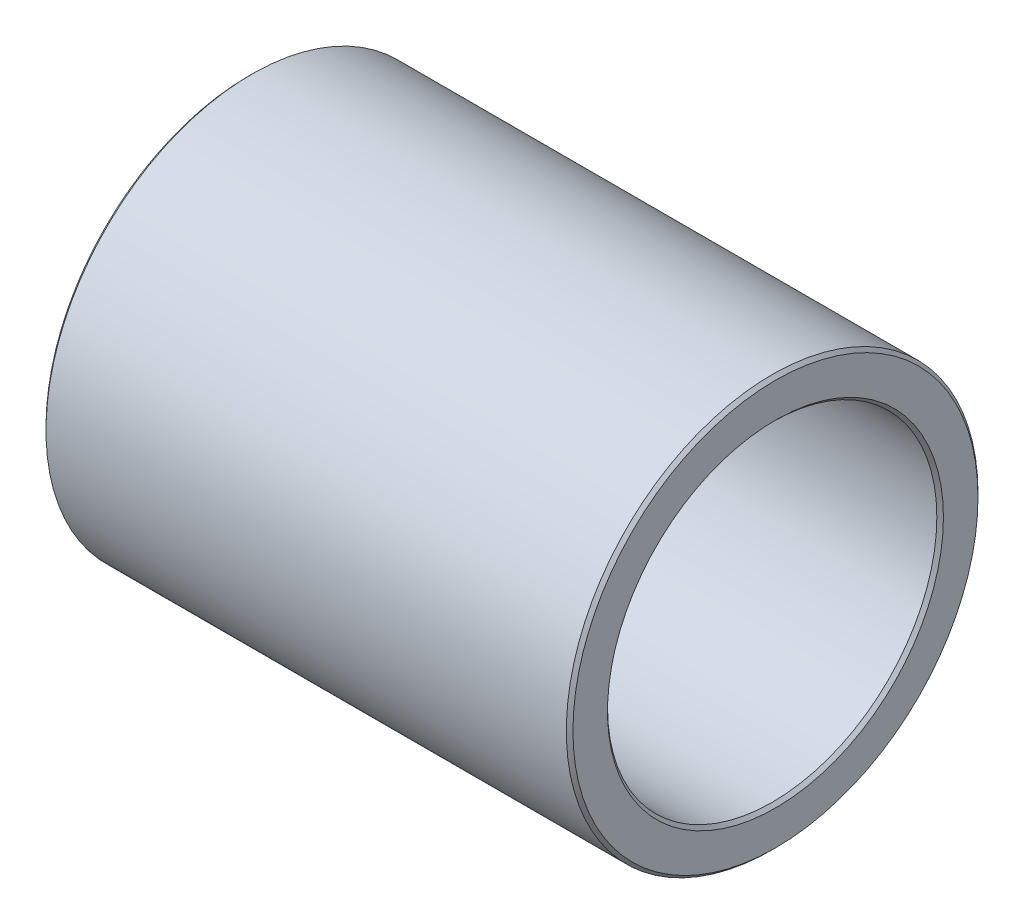
from build123d import *

# Parameters (mm, degrees)
SKETCH1_R           = 15.875
SKETCH1_R_2         = 12.7
BOSS_EXTRUDE1_DEPTH = 40.64
CHAMFER1_SIZE       = 0.254


with BuildPart() as part:
    # Sketch1 → Boss-Extrude1 (new body)
    with BuildSketch(Plane(origin=(0, 0, 0), x_dir=(0, 0, -1), z_dir=(1, 0, 0))):
        Circle(SKETCH1_R)
        Circle(SKETCH1_R_2, mode=Mode.SUBTRACT)
    extrude(amount=BOSS_EXTRUDE1_DEPTH)

    # Chamfer1
    chamfer1_edges = [part.edges().sort_by_distance(p)[0] for p in [
        (0, 0, 15.875),
        (40.64, 0, 15.875),
        (0, 0, 12.7),
        (40.64, 0, 12.7),
    ]]
    chamfer(chamfer1_edges, length=CHAMFER1_SIZE)


solid = part.part
